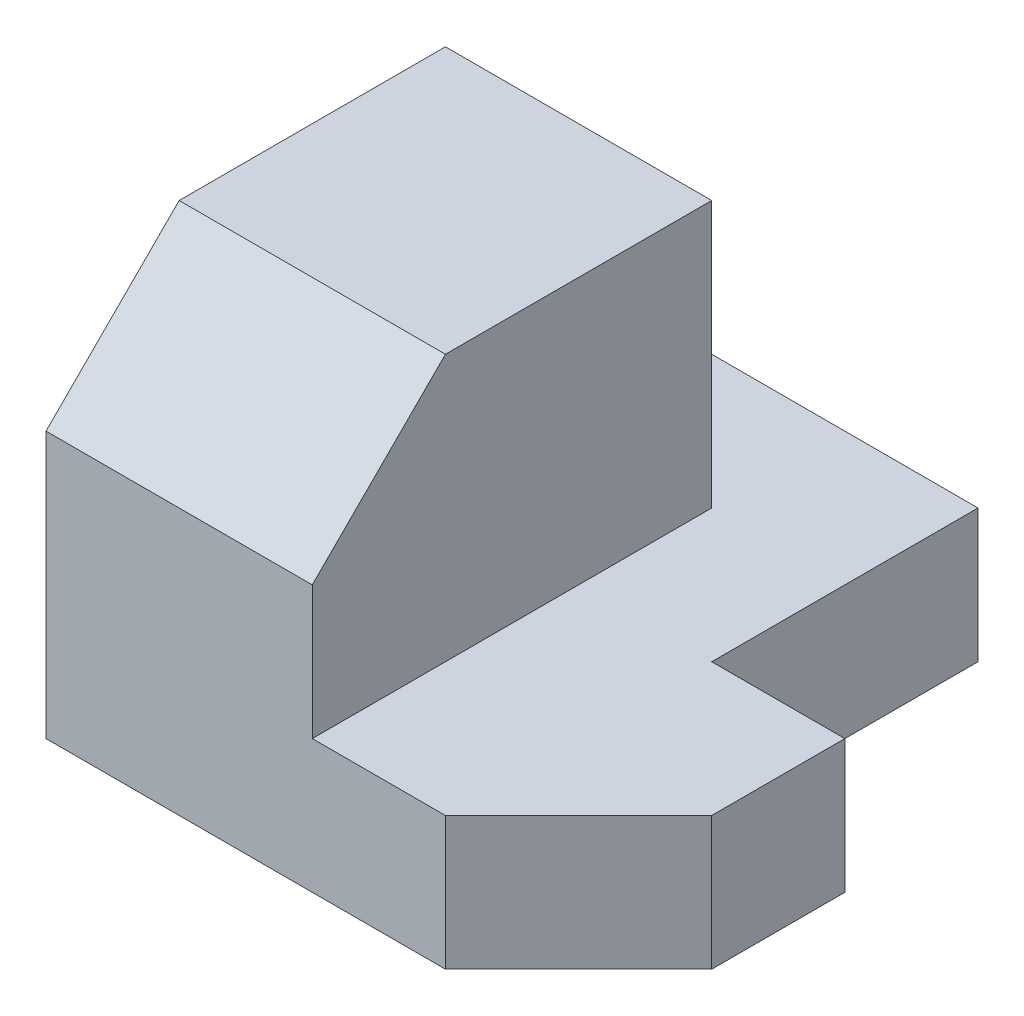
from build123d import *

# Parameters (mm, degrees)
EXTRUDE_1_DEPTH     = 1
SKETCH_1_3_W        = 2
SKETCH_1_3_H        = 3
EXTRUDE_2_DEPTH     = 3
CUT_EXTRUDE_1_DEPTH = 3


with BuildPart() as part:
    # 草圖1 → 填料-伸長1 (new body)
    with BuildSketch(Plane(origin=(0, 0, 0), x_dir=(1, 0, 0), z_dir=(0, 1, 0))):
        Polygon((0, 0), (3, 0), (4, 1), (4, 2), (3, 2), (3, 4), (0, 4), align=None)
    extrude(amount=EXTRUDE_1_DEPTH)

    # 草圖1<3> → 填料-伸長2 (add)
    with BuildSketch(Plane(origin=(0, 0, 0), x_dir=(1, 0, 0), z_dir=(0, 1, 0))):
        with Locations((1, 1.5)):
            Rectangle(SKETCH_1_3_W, SKETCH_1_3_H)
    extrude(amount=EXTRUDE_2_DEPTH)

    # 草圖2 → 除料-伸長1 (cut)
    with BuildSketch(Plane(origin=(2, 0, 0), x_dir=(0, 0, -1), z_dir=(1, 0, 0))):
        Polygon((0, 3), (0, 2), (1, 3), align=None)
    extrude(amount=-CUT_EXTRUDE_1_DEPTH, mode=Mode.SUBTRACT)


solid = part.part
